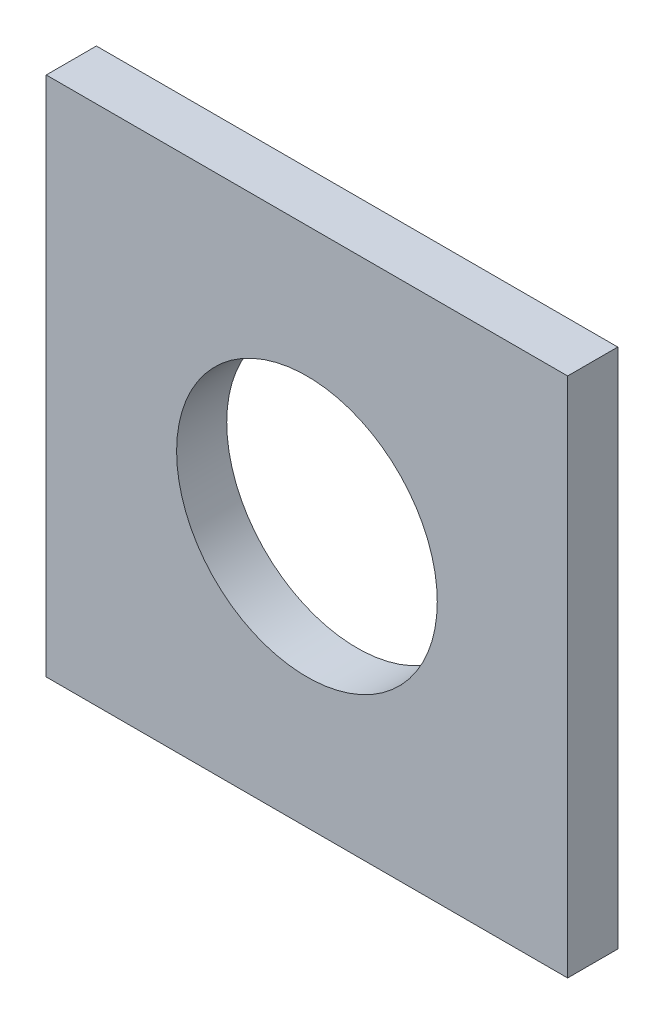
from build123d import *

# Parameters (mm, degrees)
SKETCH1_W           = 82.55
SKETCH1_H           = 82.55
SKETCH1_R           = 20.6375
BOSS_EXTRUDE1_DEPTH = 7.9375


with BuildPart() as part:
    # Sketch1 → Boss-Extrude1 (new body)
    with BuildSketch(Plane.XY):
        Rectangle(SKETCH1_W, SKETCH1_H)
        Circle(SKETCH1_R, mode=Mode.SUBTRACT)
    extrude(amount=BOSS_EXTRUDE1_DEPTH)


solid = part.part
